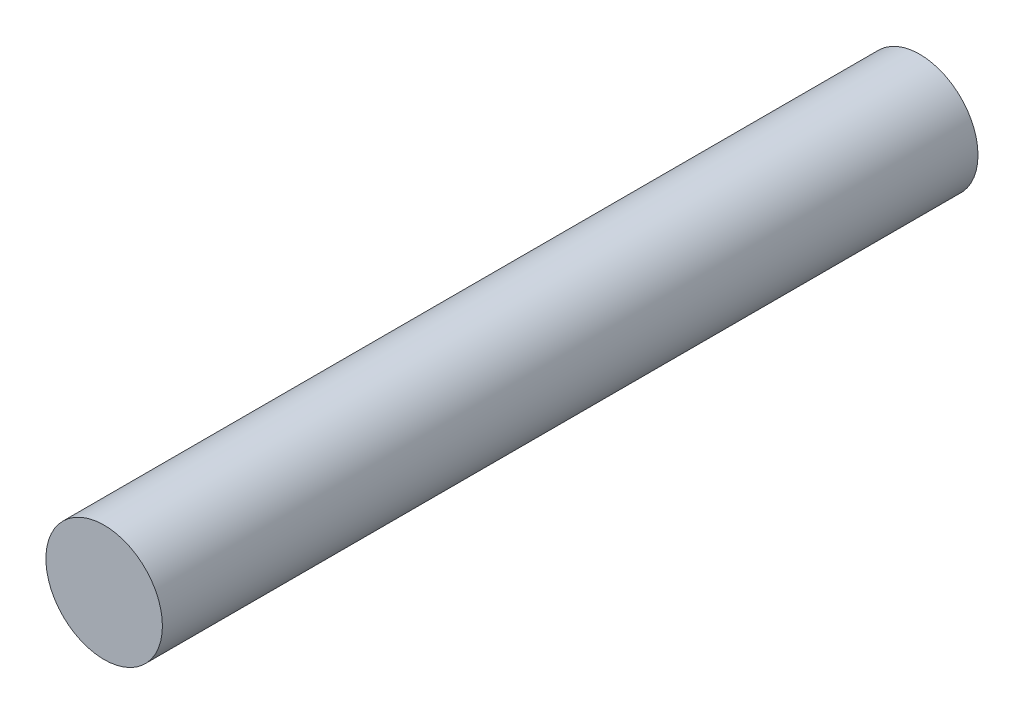
from build123d import *

# Parameters (mm, degrees)
CROQUIS1_R              = 6.35
SALIENTE_EXTRUIR1_DEPTH = 88.9


with BuildPart() as part:
    # Croquis1 → Saliente-Extruir1 (new body)
    with BuildSketch(Plane.XY):
        Circle(CROQUIS1_R)
    extrude(amount=SALIENTE_EXTRUIR1_DEPTH)


solid = part.part
